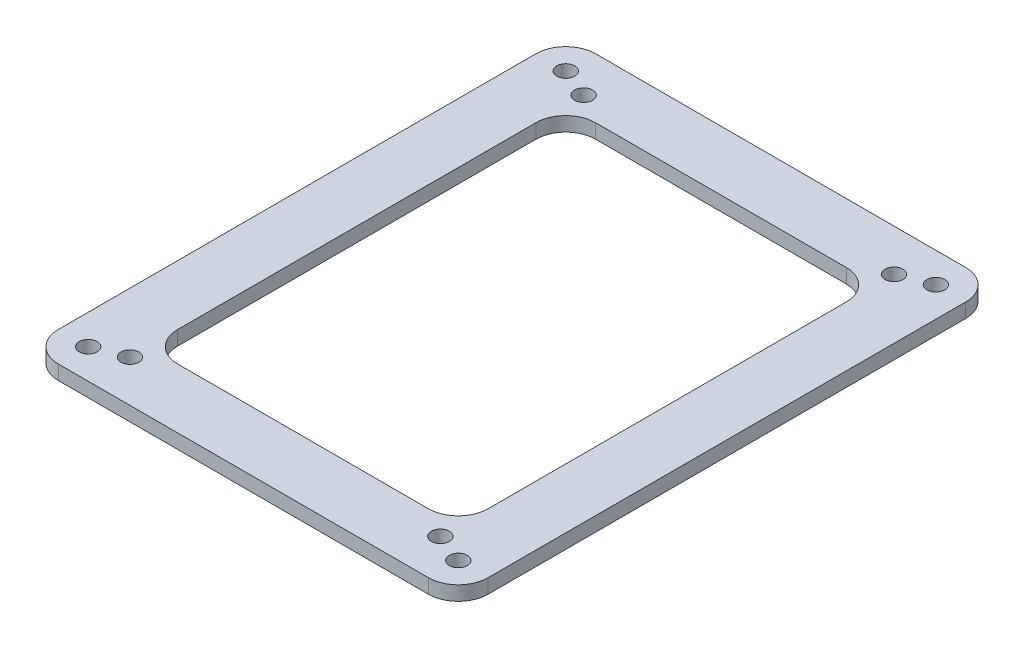
from build123d import *

# Parameters (mm, degrees)
SKETCH_1_R      = 1.5
SKETCH_1_W      = 52
SKETCH_1_H      = 70
EXTRUDE_1_DEPTH = 2.4
FILLET_1_R      = 5


with BuildPart() as part:
    # 草圖1 → 填料-伸長1 (new body)
    with BuildSketch(Plane(origin=(0, 0, 0), x_dir=(1, 0, 0), z_dir=(0, 1, 0))):
        with BuildLine():
            Line((-31, 45), (31, 45))
            ThreePointArc((31, 45), (34.535533906, 43.535533906), (36, 40))
            Line((36, 40), (36, -40))
            ThreePointArc((36, -40), (34.535533906, -43.535533906), (31, -45))
            Line((31, -45), (-31, -45))
            ThreePointArc((-31, -45), (-34.535533906, -43.535533906), (-36, -40))
            Line((-36, -40), (-36, 40))
            ThreePointArc((-36, 40), (-34.535533906, 43.535533906), (-31, 45))
        make_face()
        with Locations((-26, 38)):
            Circle(SKETCH_1_R, mode=Mode.SUBTRACT)
        with Locations((26, 38)):
            Circle(SKETCH_1_R, mode=Mode.SUBTRACT)
        with Locations((26, -38)):
            Circle(SKETCH_1_R, mode=Mode.SUBTRACT)
        with Locations((-26, -38)):
            Circle(SKETCH_1_R, mode=Mode.SUBTRACT)
        with Locations((-31, 40)):
            Circle(SKETCH_1_R, mode=Mode.SUBTRACT)
        with Locations((31, 40)):
            Circle(SKETCH_1_R, mode=Mode.SUBTRACT)
        with Locations((-31, -40)):
            Circle(SKETCH_1_R, mode=Mode.SUBTRACT)
        with Locations((31, -40)):
            Circle(SKETCH_1_R, mode=Mode.SUBTRACT)
        Rectangle(SKETCH_1_W, SKETCH_1_H, mode=Mode.SUBTRACT)
    extrude(amount=EXTRUDE_1_DEPTH)

    # 圓角1
    fillet_1_edges = [part.edges().sort_by_distance(p)[0] for p in [
        (26, 1.2, -35),
        (-26, 1.2, -35),
        (-26, 1.2, 35),
        (26, 1.2, 35),
    ]]
    fillet(fillet_1_edges, radius=FILLET_1_R)


solid = part.part
